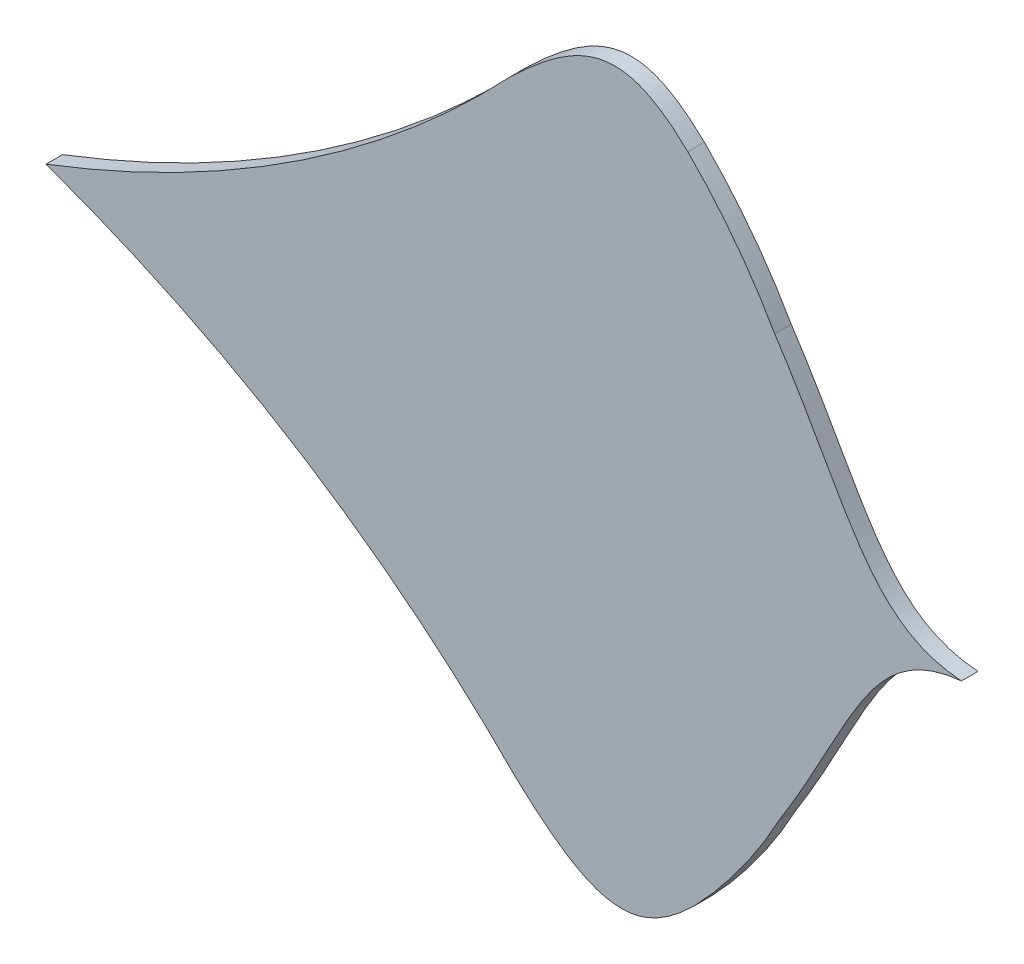
from build123d import *

# Parameters (mm, degrees)
BOSS_EXTRUDE1_DEPTH = 10


with BuildPart() as part:
    # Sketch1 → Boss-Extrude1 (new body)
    with BuildSketch(Plane.XY):
        with BuildLine():
            add(Edge.make_bspline(
                [(409.224868449, 431.812362674), (353.208318775, 435.814996738), (341.801830867, 488.161683055), (296.446812903, 556.976193069)],
                knots=[0, 0, 0, 0, 1, 1, 1, 1], degree=3))
            add(Edge.make_bspline(
                [(296.446812903, 556.976193069), (281.932763026, 582.589222263), (264.405949262, 605.591633402), (243.960653378, 626.036929287)],
                knots=[0, 0, 0, 0, 1, 1, 1, 1], degree=3))
            add(Edge.make_bspline(
                [(243.960653378, 626.036929287), (206.568548088, 661.953958927), (181.063496859, 654.384446294), (136.216103642, 611.031966185)],
                knots=[0, 0, 0, 0, 1, 1, 1, 1], degree=3))
            add(Edge.make_bspline(
                [(136.216103642, 611.031966185), (21.148921326, 488.871601397), (-143.606904725, 425.684916913)],
                knots=[0, 0, 0, 1, 1, 1], degree=2))
            add(Edge.make_bspline(
                [(140.255533668, 246.58561274), (22.508963994, 366.165529538), (-143.606904725, 425.684916913)],
                knots=[0, 0, 0, 1, 1, 1], degree=2))
            add(Edge.make_bspline(
                [(248.306195431, 233.972468485), (211.719368719, 197.235475313), (186.052806813, 204.237814893), (140.255533668, 246.58561274)],
                knots=[0, 0, 0, 0, 1, 1, 1, 1], degree=3))
            add(Edge.make_bspline(
                [(299.248745784, 304.179582029), (285.30596832, 278.25114465), (268.293303375, 254.865906777), (248.306195431, 233.972468485)],
                knots=[0, 0, 0, 0, 1, 1, 1, 1], degree=3))
            add(Edge.make_bspline(
                [(409.224868449, 431.812362674), (353.310797723, 426.569118286), (343.067364019, 373.982469784), (299.248745784, 304.179582029)],
                knots=[0, 0, 0, 0, 1, 1, 1, 1], degree=3))
        make_face()
    extrude(amount=BOSS_EXTRUDE1_DEPTH)


solid = part.part
